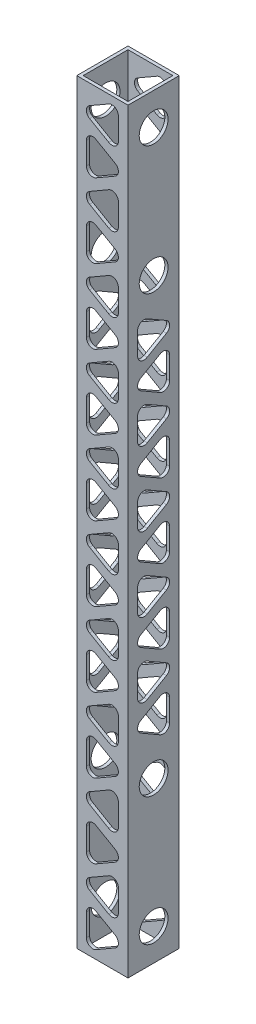
from build123d import *

# Parameters (mm, degrees)
SKETCH1_W           = 50.8
SKETCH1_H           = 50.8
SKETCH1_W_2         = 44.45
SKETCH1_H_2         = 44.45
BOSS_EXTRUDE1_DEPTH = 749.3
SKETCH2_R           = 14.2875
CUT_EXTRUDE1_DEPTH  = 51.8
CUT_EXTRUDE2_DEPTH  = 71.12
CUT_EXTRUDE3_DEPTH  = 71.12


with BuildPart() as part:
    # Sketch1 → Boss-Extrude1 (new body)
    with BuildSketch(Plane(origin=(0, 0, 0), x_dir=(1, 0, 0), z_dir=(0, 1, 0))):
        Rectangle(SKETCH1_W, SKETCH1_H)
        Rectangle(SKETCH1_W_2, SKETCH1_H_2, mode=Mode.SUBTRACT)
    extrude(amount=BOSS_EXTRUDE1_DEPTH)

    # Sketch2 → Cut-Extrude1 (cut, through all)
    with BuildSketch(Plane.ZY.offset(25.4)):
        with Locations((0, 31.75)):
            Circle(SKETCH2_R)
        with Locations((0, 158.75)):
            Circle(SKETCH2_R)
        with Locations((0, 590.55)):
            Circle(SKETCH2_R)
        with Locations((0, 717.55)):
            Circle(SKETCH2_R)
    extrude(amount=-CUT_EXTRUDE1_DEPTH, mode=Mode.SUBTRACT)

    # Sketch3 → Cut-Extrude2 (cut)
    with BuildSketch(Plane(origin=(25.4, 0, 0), x_dir=(0, 0, -1), z_dir=(1, 0, 0))):
        with BuildLine():
            Line((-12.7, 203.879605328), (6.35, 192.8810827))
            ThreePointArc((6.35, 192.8810827), (12.7, 192.8810827), (15.875, 198.380344014))
            Line((15.875, 198.380344014), (15.875, 220.37738927))
            ThreePointArc((15.875, 220.37738927), (12.7, 225.876650584), (6.35, 225.876650584))
            Line((6.35, 225.876650584), (-12.7, 214.878127956))
            ThreePointArc((-12.7, 214.878127956), (-15.875, 209.378866642), (-12.7, 203.879605328))
        make_face()
        with BuildLine():
            Line((12.7, 251.53987005), (-6.35, 262.538392678))
            ThreePointArc((-6.35, 262.538392678), (-12.7, 262.538392678), (-15.875, 257.039131364))
            Line((-15.875, 257.039131364), (-15.875, 235.042086108))
            ThreePointArc((-15.875, 235.042086108), (-12.7, 229.542824794), (-6.35, 229.542824794))
            Line((-6.35, 229.542824794), (12.7, 240.541347422))
            ThreePointArc((12.7, 240.541347422), (15.875, 246.040608736), (12.7, 251.53987005))
        make_face()
        with BuildLine():
            Line((-12.7, 277.349736484), (6.35, 266.351213856))
            ThreePointArc((6.35, 266.351213856), (12.7, 266.351213856), (15.875, 271.85047517))
            Line((15.875, 271.85047517), (15.875, 293.847520426))
            ThreePointArc((15.875, 293.847520426), (12.7, 299.34678174), (6.35, 299.34678174))
            Line((6.35, 299.34678174), (-12.7, 288.348259112))
            ThreePointArc((-12.7, 288.348259112), (-15.875, 282.848997798), (-12.7, 277.349736484))
        make_face()
        with BuildLine():
            Line((12.7, 325.010001205), (-6.35, 336.008523833))
            ThreePointArc((-6.35, 336.008523833), (-12.7, 336.008523833), (-15.875, 330.509262519))
            Line((-15.875, 330.509262519), (-15.875, 308.512217263))
            ThreePointArc((-15.875, 308.512217263), (-12.7, 303.012955949), (-6.35, 303.012955949))
            Line((-6.35, 303.012955949), (12.7, 314.011478577))
            ThreePointArc((12.7, 314.011478577), (15.875, 319.510739891), (12.7, 325.010001205))
        make_face()
        with BuildLine():
            Line((-12.7, 350.819867639), (6.35, 339.821345011))
            ThreePointArc((6.35, 339.821345011), (12.7, 339.821345011), (15.875, 345.320606325))
            Line((15.875, 345.320606325), (15.875, 367.317651581))
            ThreePointArc((15.875, 367.317651581), (12.7, 372.816912895), (6.35, 372.816912895))
            Line((6.35, 372.816912895), (-12.7, 361.818390267))
            ThreePointArc((-12.7, 361.818390267), (-15.875, 356.319128953), (-12.7, 350.819867639))
        make_face()
        with BuildLine():
            Line((12.7, 398.480132361), (-6.35, 409.478654989))
            ThreePointArc((-6.35, 409.478654989), (-12.7, 409.478654989), (-15.875, 403.979393675))
            Line((-15.875, 403.979393675), (-15.875, 381.982348419))
            ThreePointArc((-15.875, 381.982348419), (-12.7, 376.483087105), (-6.35, 376.483087105))
            Line((-6.35, 376.483087105), (12.7, 387.481609733))
            ThreePointArc((12.7, 387.481609733), (15.875, 392.980871047), (12.7, 398.480132361))
        make_face()
        with BuildLine():
            Line((-12.7, 424.289998795), (6.35, 413.291476167))
            ThreePointArc((6.35, 413.291476167), (12.7, 413.291476167), (15.875, 418.790737481))
            Line((15.875, 418.790737481), (15.875, 440.787782737))
            ThreePointArc((15.875, 440.787782737), (12.7, 446.287044051), (6.35, 446.287044051))
            Line((6.35, 446.287044051), (-12.7, 435.288521423))
            ThreePointArc((-12.7, 435.288521423), (-15.875, 429.789260109), (-12.7, 424.289998795))
        make_face()
        with BuildLine():
            Line((12.7, 471.950263516), (-6.35, 482.948786144))
            ThreePointArc((-6.35, 482.948786144), (-12.7, 482.948786144), (-15.875, 477.44952483))
            Line((-15.875, 477.44952483), (-15.875, 455.452479574))
            ThreePointArc((-15.875, 455.452479574), (-12.7, 449.95321826), (-6.35, 449.95321826))
            Line((-6.35, 449.95321826), (12.7, 460.951740888))
            ThreePointArc((12.7, 460.951740888), (15.875, 466.451002202), (12.7, 471.950263516))
        make_face()
        with BuildLine():
            Line((-12.7, 497.76012995), (6.35, 486.761607322))
            ThreePointArc((6.35, 486.761607322), (12.7, 486.761607322), (15.875, 492.260868636))
            Line((15.875, 492.260868636), (15.875, 514.257913892))
            ThreePointArc((15.875, 514.257913892), (12.7, 519.757175206), (6.35, 519.757175206))
            Line((6.35, 519.757175206), (-12.7, 508.758652578))
            ThreePointArc((-12.7, 508.758652578), (-15.875, 503.259391264), (-12.7, 497.76012995))
        make_face()
        with BuildLine():
            Line((12.7, 545.420394672), (-6.35, 556.4189173))
            ThreePointArc((-6.35, 556.4189173), (-12.7, 556.4189173), (-15.875, 550.919655986))
            Line((-15.875, 550.919655986), (-15.875, 528.92261073))
            ThreePointArc((-15.875, 528.92261073), (-12.7, 523.423349416), (-6.35, 523.423349416))
            Line((-6.35, 523.423349416), (12.7, 534.421872044))
            ThreePointArc((12.7, 534.421872044), (15.875, 539.921133358), (12.7, 545.420394672))
        make_face()
    extrude(amount=-CUT_EXTRUDE2_DEPTH, mode=Mode.SUBTRACT)

    # Sketch5 → Cut-Extrude3 (cut)
    with BuildSketch(Plane(origin=(0, 0, -25.4), x_dir=(-1, 0, 0), z_dir=(0, 0, -1))):
        with BuildLine():
            Line((12.7, 729.828957402), (-6.35, 740.82748003))
            ThreePointArc((-6.35, 740.82748003), (-12.7, 740.82748003), (-15.875, 735.328218716))
            Line((-15.875, 735.328218716), (-15.875, 713.33117346))
            ThreePointArc((-15.875, 713.33117346), (-12.7, 707.831912146), (-6.35, 707.831912146))
            Line((-6.35, 707.831912146), (12.7, 718.830434774))
            ThreePointArc((12.7, 718.830434774), (15.875, 724.329696088), (12.7, 729.828957402))
        make_face()
        with BuildLine():
            Line((-12.7, 682.022045712), (6.35, 671.023523084))
            ThreePointArc((6.35, 671.023523084), (12.7, 671.023523084), (15.875, 676.522784398))
            Line((15.875, 676.522784398), (15.875, 698.519829654))
            ThreePointArc((15.875, 698.519829654), (12.7, 704.019090968), (6.35, 704.019090968))
            Line((6.35, 704.019090968), (-12.7, 693.02056834))
            ThreePointArc((-12.7, 693.02056834), (-15.875, 687.521307026), (-12.7, 682.022045712))
        make_face()
        with BuildLine():
            Line((12.7, 656.212179278), (-6.35, 667.210701906))
            ThreePointArc((-6.35, 667.210701906), (-12.7, 667.210701906), (-15.875, 661.711440592))
            Line((-15.875, 661.711440592), (-15.875, 639.714395336))
            ThreePointArc((-15.875, 639.714395336), (-12.7, 634.215134022), (-6.35, 634.215134022))
            Line((-6.35, 634.215134022), (12.7, 645.21365665))
            ThreePointArc((12.7, 645.21365665), (15.875, 650.712917964), (12.7, 656.212179278))
        make_face()
        with BuildLine():
            Line((-12.7, 608.405267588), (6.35, 597.40674496))
            ThreePointArc((6.35, 597.40674496), (12.7, 597.40674496), (15.875, 602.906006274))
            Line((15.875, 602.906006274), (15.875, 624.903051531))
            ThreePointArc((15.875, 624.903051531), (12.7, 630.402312845), (6.35, 630.402312845))
            Line((6.35, 630.402312845), (-12.7, 619.403790216))
            ThreePointArc((-12.7, 619.403790216), (-15.875, 613.904528902), (-12.7, 608.405267588))
        make_face()
        with BuildLine():
            Line((12.7, 582.595401155), (-6.35, 593.593923783))
            ThreePointArc((-6.35, 593.593923783), (-12.7, 593.593923783), (-15.875, 588.094662469))
            Line((-15.875, 588.094662469), (-15.875, 566.097617212))
            ThreePointArc((-15.875, 566.097617212), (-12.7, 560.598355898), (-6.35, 560.598355898))
            Line((-6.35, 560.598355898), (12.7, 571.596878526))
            ThreePointArc((12.7, 571.596878526), (15.875, 577.096139841), (12.7, 582.595401155))
        make_face()
        with BuildLine():
            Line((-12.7, 534.788489465), (6.35, 523.789966837))
            ThreePointArc((6.35, 523.789966837), (12.7, 523.789966837), (15.875, 529.289228151))
            Line((15.875, 529.289228151), (15.875, 551.286273407))
            ThreePointArc((15.875, 551.286273407), (12.7, 556.785534721), (6.35, 556.785534721))
            Line((6.35, 556.785534721), (-12.7, 545.787012093))
            ThreePointArc((-12.7, 545.787012093), (-15.875, 540.287750779), (-12.7, 534.788489465))
        make_face()
        with BuildLine():
            Line((12.7, 508.978623031), (-6.35, 519.977145659))
            ThreePointArc((-6.35, 519.977145659), (-12.7, 519.977145659), (-15.875, 514.477884345))
            Line((-15.875, 514.477884345), (-15.875, 492.480839089))
            ThreePointArc((-15.875, 492.480839089), (-12.7, 486.981577775), (-6.35, 486.981577775))
            Line((-6.35, 486.981577775), (12.7, 497.980100403))
            ThreePointArc((12.7, 497.980100403), (15.875, 503.479361717), (12.7, 508.978623031))
        make_face()
        with BuildLine():
            Line((-12.7, 461.171711341), (6.35, 450.173188713))
            ThreePointArc((6.35, 450.173188713), (12.7, 450.173188713), (15.875, 455.672450027))
            Line((15.875, 455.672450027), (15.875, 477.669495283))
            ThreePointArc((15.875, 477.669495283), (12.7, 483.168756597), (6.35, 483.168756597))
            Line((6.35, 483.168756597), (-12.7, 472.170233969))
            ThreePointArc((-12.7, 472.170233969), (-15.875, 466.670972655), (-12.7, 461.171711341))
        make_face()
        with BuildLine():
            Line((12.7, 435.361844907), (-6.35, 446.360367535))
            ThreePointArc((-6.35, 446.360367535), (-12.7, 446.360367535), (-15.875, 440.861106221))
            Line((-15.875, 440.861106221), (-15.875, 418.864060965))
            ThreePointArc((-15.875, 418.864060965), (-12.7, 413.364799651), (-6.35, 413.364799651))
            Line((-6.35, 413.364799651), (12.7, 424.363322279))
            ThreePointArc((12.7, 424.363322279), (15.875, 429.862583593), (12.7, 435.361844907))
        make_face()
        with BuildLine():
            Line((-12.7, 387.554933217), (6.35, 376.556410589))
            ThreePointArc((6.35, 376.556410589), (12.7, 376.556410589), (15.875, 382.055671903))
            Line((15.875, 382.055671903), (15.875, 404.052717159))
            ThreePointArc((15.875, 404.052717159), (12.7, 409.551978473), (6.35, 409.551978473))
            Line((6.35, 409.551978473), (-12.7, 398.553455845))
            ThreePointArc((-12.7, 398.553455845), (-15.875, 393.054194531), (-12.7, 387.554933217))
        make_face()
        with BuildLine():
            Line((12.7, 361.745066783), (-6.35, 372.743589411))
            ThreePointArc((-6.35, 372.743589411), (-12.7, 372.743589411), (-15.875, 367.244328097))
            Line((-15.875, 367.244328097), (-15.875, 345.247282841))
            ThreePointArc((-15.875, 345.247282841), (-12.7, 339.748021527), (-6.35, 339.748021527))
            Line((-6.35, 339.748021527), (12.7, 350.746544155))
            ThreePointArc((12.7, 350.746544155), (15.875, 356.245805469), (12.7, 361.745066783))
        make_face()
        with BuildLine():
            Line((-12.7, 313.938155093), (6.35, 302.939632465))
            ThreePointArc((6.35, 302.939632465), (12.7, 302.939632465), (15.875, 308.438893779))
            Line((15.875, 308.438893779), (15.875, 330.435939035))
            ThreePointArc((15.875, 330.435939035), (12.7, 335.935200349), (6.35, 335.935200349))
            Line((6.35, 335.935200349), (-12.7, 324.936677721))
            ThreePointArc((-12.7, 324.936677721), (-15.875, 319.437416407), (-12.7, 313.938155093))
        make_face()
        with BuildLine():
            Line((12.7, 288.128288659), (-6.35, 299.126811287))
            ThreePointArc((-6.35, 299.126811287), (-12.7, 299.126811287), (-15.875, 293.627549973))
            Line((-15.875, 293.627549973), (-15.875, 271.630504717))
            ThreePointArc((-15.875, 271.630504717), (-12.7, 266.131243403), (-6.35, 266.131243403))
            Line((-6.35, 266.131243403), (12.7, 277.129766031))
            ThreePointArc((12.7, 277.129766031), (15.875, 282.629027345), (12.7, 288.128288659))
        make_face()
        with BuildLine():
            Line((-12.7, 240.321376969), (6.35, 229.322854341))
            ThreePointArc((6.35, 229.322854341), (12.7, 229.322854341), (15.875, 234.822115655))
            Line((15.875, 234.822115655), (15.875, 256.819160911))
            ThreePointArc((15.875, 256.819160911), (12.7, 262.318422225), (6.35, 262.318422225))
            Line((6.35, 262.318422225), (-12.7, 251.319899597))
            ThreePointArc((-12.7, 251.319899597), (-15.875, 245.820638283), (-12.7, 240.321376969))
        make_face()
        with BuildLine():
            Line((12.7, 214.511510535), (-6.35, 225.510033163))
            ThreePointArc((-6.35, 225.510033163), (-12.7, 225.510033163), (-15.875, 220.010771849))
            Line((-15.875, 220.010771849), (-15.875, 198.013726593))
            ThreePointArc((-15.875, 198.013726593), (-12.7, 192.514465279), (-6.35, 192.514465279))
            Line((-6.35, 192.514465279), (12.7, 203.512987907))
            ThreePointArc((12.7, 203.512987907), (15.875, 209.012249221), (12.7, 214.511510535))
        make_face()
        with BuildLine():
            Line((-12.7, 166.704598845), (6.35, 155.706076217))
            ThreePointArc((6.35, 155.706076217), (12.7, 155.706076217), (15.875, 161.205337531))
            Line((15.875, 161.205337531), (15.875, 183.202382788))
            ThreePointArc((15.875, 183.202382788), (12.7, 188.701644102), (6.35, 188.701644102))
            Line((6.35, 188.701644102), (-12.7, 177.703121473))
            ThreePointArc((-12.7, 177.703121473), (-15.875, 172.203860159), (-12.7, 166.704598845))
        make_face()
        with BuildLine():
            Line((12.7, 140.894732412), (-6.35, 151.89325504))
            ThreePointArc((-6.35, 151.89325504), (-12.7, 151.89325504), (-15.875, 146.393993726))
            Line((-15.875, 146.393993726), (-15.875, 124.396948469))
            ThreePointArc((-15.875, 124.396948469), (-12.7, 118.897687155), (-6.35, 118.897687155))
            Line((-6.35, 118.897687155), (12.7, 129.896209784))
            ThreePointArc((12.7, 129.896209784), (15.875, 135.395471098), (12.7, 140.894732412))
        make_face()
        with BuildLine():
            Line((-12.7, 93.087820722), (6.35, 82.089298094))
            ThreePointArc((6.35, 82.089298094), (12.7, 82.089298094), (15.875, 87.588559408))
            Line((15.875, 87.588559408), (15.875, 109.585604664))
            ThreePointArc((15.875, 109.585604664), (12.7, 115.084865978), (6.35, 115.084865978))
            Line((6.35, 115.084865978), (-12.7, 104.08634335))
            ThreePointArc((-12.7, 104.08634335), (-15.875, 98.587082036), (-12.7, 93.087820722))
        make_face()
        with BuildLine():
            Line((12.7, 67.277954288), (-6.35, 78.276476916))
            ThreePointArc((-6.35, 78.276476916), (-12.7, 78.276476916), (-15.875, 72.777215602))
            Line((-15.875, 72.777215602), (-15.875, 50.780170346))
            ThreePointArc((-15.875, 50.780170346), (-12.7, 45.280909032), (-6.35, 45.280909032))
            Line((-6.35, 45.280909032), (12.7, 56.27943166))
            ThreePointArc((12.7, 56.27943166), (15.875, 61.778692974), (12.7, 67.277954288))
        make_face()
        with BuildLine():
            Line((-12.7, 19.471042598), (6.35, 8.47251997))
            ThreePointArc((6.35, 8.47251997), (12.7, 8.47251997), (15.875, 13.971781284))
            Line((15.875, 13.971781284), (15.875, 35.96882654))
            ThreePointArc((15.875, 35.96882654), (12.7, 41.468087854), (6.35, 41.468087854))
            Line((6.35, 41.468087854), (-12.7, 30.469565226))
            ThreePointArc((-12.7, 30.469565226), (-15.875, 24.970303912), (-12.7, 19.471042598))
        make_face()
    extrude(amount=-CUT_EXTRUDE3_DEPTH, mode=Mode.SUBTRACT)


solid = part.part
